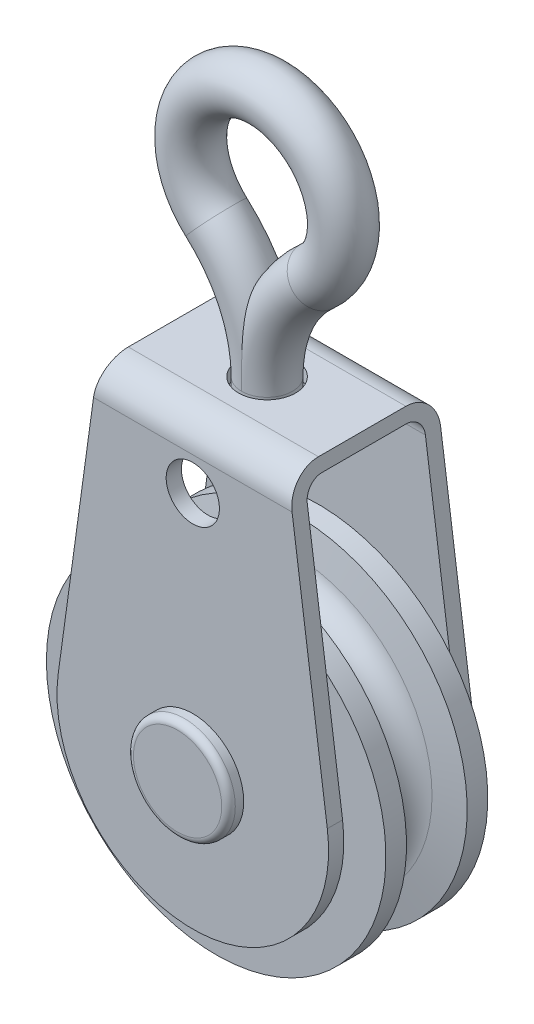
from build123d import *

# Parameters (mm, degrees)
REVOLVE1_ANGLE           = 360
SKETCH3_R                = 2.4892
BOSS_EXTRUDE1_DEPTH      = 1.4224
BOSS_EXTRUDE2_DEPTH      = 5.5245
FILLET1_R                = 1.5875
FILLET2_R                = 2.8575
SKETCH5_R                = 2.667
CUT_EXTRUDE1_DEPTH       = 1.27
SKETCH6_R                = 4.7625
BOSS_EXTRUDE3_DEPTH      = 1.4224
FILLET3_R                = 0.635
SKETCH7_R                = 2.8575
BOSS_EXTRUDE4_DEPTH      = 13.7414
SKETCH8_R                = 2.38125
SKETCH10_R               = 2.38125
BOSS_EXTRUDE5_DEPTH      = 1.524
SKETCH11_R               = 3.96875
BOSS_EXTRUDE6_DEPTH      = 1.778
BOSS_EXTRUDE6_DEPTH_BACK = 0.254


with BuildPart() as part:
    # Sketch2 → Revolve1 (revolve, symmetric)
    with BuildSketch(Plane(origin=(0, 0, 0), x_dir=(0, 0, -1), z_dir=(1, 0, 0))) as revolve1_sk:
        with BuildLine():
            Line((-2.345073462, 13.080250277), (-2.837863242, 15.875))
            Line((-2.837863242, 15.875), (-4.7625, 15.875))
            Line((-4.7625, 15.875), (-4.7625, 0))
            Line((-4.7625, 0), (4.7625, 0))
            Line((4.7625, 0), (4.7625, 15.875))
            Line((4.7625, 15.875), (2.837863242, 15.875))
            Line((2.837863242, 15.875), (2.345073462, 13.080250277))
            ThreePointArc((2.345073462, 13.080250277), (0, 11.1125), (-2.345073462, 13.080250277))
        make_face()
    revolve(axis=Axis((0, 0, -4.7625), (0, 0, 1)), revolution_arc=REVOLVE1_ANGLE / 2)
    revolve(revolve1_sk.sketch, axis=Axis((0, 0, -4.7625), (0, 0, -1)), revolution_arc=REVOLVE1_ANGLE / 2)



with BuildPart() as body_2:
    # Sketch3 → Boss-Extrude1 (new body)
    with BuildSketch(Plane.XY.offset(5.5245)):
        with BuildLine():
            Line((-8.89, 28.575), (8.89, 28.575))
            Line((8.89, 28.575), (12.581594065, 1.730170735))
            ThreePointArc((12.581594065, 1.730170735), (0, -12.7), (-12.581594065, 1.730170735))
            Line((-12.581594065, 1.730170735), (-8.89, 28.575))
        make_face()
        with Locations((0, 22.606)):
            Circle(SKETCH3_R, mode=Mode.SUBTRACT)
    extrude(amount=BOSS_EXTRUDE1_DEPTH)

    # Sketch4 → Boss-Extrude2 (add)
    with BuildSketch(Plane(origin=(0, 0, 5.5245), x_dir=(-1, 0, 0), z_dir=(0, 0, -1))):
        Polygon((-9.064645345, 27.305), (9.064645345, 27.305), (8.89, 28.575), (-8.89, 28.575), align=None)
    extrude(amount=BOSS_EXTRUDE2_DEPTH)

    # Fillet1
    fillet1_edges = [body_2.edges().sort_by_distance(p)[0] for p in [
        (0, 27.305, 5.5245),
    ]]
    fillet(fillet1_edges, radius=FILLET1_R)

    # Fillet2
    fillet2_edges = [body_2.edges().sort_by_distance(p)[0] for p in [
        (0, 28.575, 6.9469),
    ]]
    fillet(fillet2_edges, radius=FILLET2_R)


with BuildPart() as body_3:
    # Mirror1: mirrored copy
    add(body_2.part.mirror(Plane.XY))


with BuildPart() as cut_extrude1_tool:
    # Sketch5 → Cut-Extrude1 (new body)
    with BuildSketch(Plane(origin=(0, 28.575, 0), x_dir=(1, 0, 0), z_dir=(0, 1, 0))):
        Circle(SKETCH5_R)
    extrude(amount=-CUT_EXTRUDE1_DEPTH)


with BuildPart() as body_2_1:
    add(body_2.part)

    # Cut-Extrude1: cut by cut_extrude1_tool
    add(cut_extrude1_tool.part, mode=Mode.SUBTRACT)

    # Sketch6 → Boss-Extrude3 (add)
    with BuildSketch(Plane.XY.offset(6.9469)):
        Circle(SKETCH6_R)
    extrude(amount=BOSS_EXTRUDE3_DEPTH)

    # Fillet3
    fillet3_edges = [body_2_1.edges().sort_by_distance(p)[0] for p in [
        (-4.7625, 0, 8.3693),
    ]]
    fillet(fillet3_edges, radius=FILLET3_R)


with BuildPart() as body_3_1:
    add(body_3.part)

    # Cut-Extrude1: cut by cut_extrude1_tool
    add(cut_extrude1_tool.part, mode=Mode.SUBTRACT)


with BuildPart() as part_1:
    add(part.part)

    add(body_2_1.part)  # Boss-Extrude4 merges body 2

    add(body_3_1.part)  # Boss-Extrude4 merges body 3
    # Sketch7 → Boss-Extrude4 (add)
    with BuildSketch(Plane(origin=(0, 0, 5.5245), x_dir=(-1, 0, 0), z_dir=(0, 0, -1))):
        Circle(SKETCH7_R)
    extrude(amount=BOSS_EXTRUDE4_DEPTH)



with BuildPart() as body_2_2:
    # Sweep1: sweep along a path in Sketch9
    with BuildLine(Plane.XY) as sweep1_path:
        ThreePointArc((-2.38125, 28.575), (-3.410514494, 33.370424728), (-6.316995842, 37.321101871))
        ThreePointArc((-6.316995842, 37.321101871), (-8.905851438, 47.82808158), (0, 53.975))
    # Sketch8 → Sweep1 (sweep)
    with BuildSketch(Plane(origin=(0, 28.575, 0), x_dir=(1, 0, 0), z_dir=(0, 1, 0))):
        Circle(SKETCH8_R)
    sweep1 = sweep(path=sweep1_path.line)

    # Mirror3: Sweep1 across plane
    add(sweep1.mirror(Plane(origin=(0, 0, 0), x_dir=(0, 0, 1), z_dir=(1, 0, 0))))

    # Sketch10 → Boss-Extrude5 (add)
    with BuildSketch(Plane.XZ.offset(-28.575)):
        Circle(SKETCH10_R)
    extrude(amount=BOSS_EXTRUDE5_DEPTH)


with BuildPart() as part_2:
    add(part_1.part)

    add(body_2_2.part)  # Boss-Extrude6 merges body 2 2
    # Sketch11 → Boss-Extrude6 (add, two sides)
    with BuildSketch(Plane.XZ.offset(-27.051)) as boss_extrude6_sk:
        Circle(SKETCH11_R)
    extrude(amount=BOSS_EXTRUDE6_DEPTH)
    extrude(boss_extrude6_sk.sketch, amount=-BOSS_EXTRUDE6_DEPTH_BACK)


solid = part_2.part
